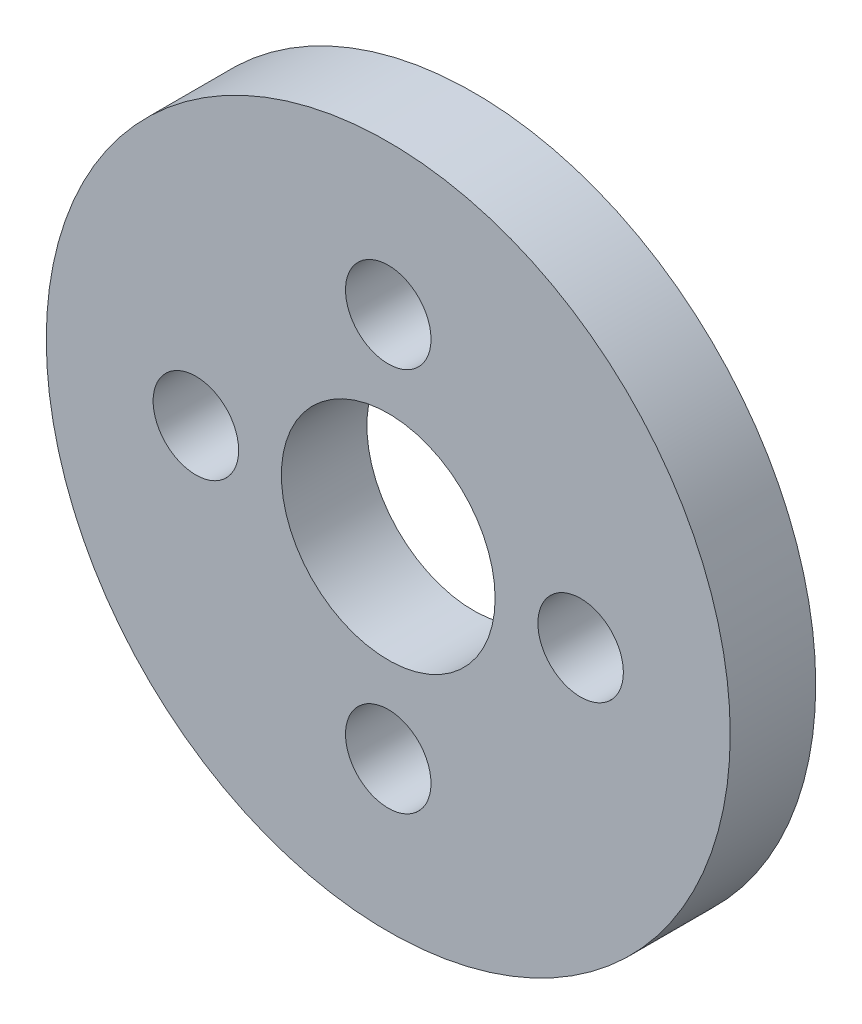
from build123d import *

# Parameters (mm, degrees)
SKETCH1_R           = 25.4
SKETCH1_R_2         = 7.9375
SKETCH1_R_3         = 3.175
BOSS_EXTRUDE1_DEPTH = 6.35


with BuildPart() as part:
    # Sketch1 → Boss-Extrude1 (new body)
    with BuildSketch(Plane.XY):
        with Locations((0, 228.6)):
            Circle(SKETCH1_R)
        with Locations((0, 228.6)):
            Circle(SKETCH1_R_2, mode=Mode.SUBTRACT)
        with Locations((0, 242.8875)):
            Circle(SKETCH1_R_3, mode=Mode.SUBTRACT)
        with Locations((14.2875, 228.6)):
            Circle(SKETCH1_R_3, mode=Mode.SUBTRACT)
        with Locations((0, 214.3125)):
            Circle(SKETCH1_R_3, mode=Mode.SUBTRACT)
        with Locations((-14.2875, 228.6)):
            Circle(SKETCH1_R_3, mode=Mode.SUBTRACT)
    extrude(amount=BOSS_EXTRUDE1_DEPTH)


solid = part.part
